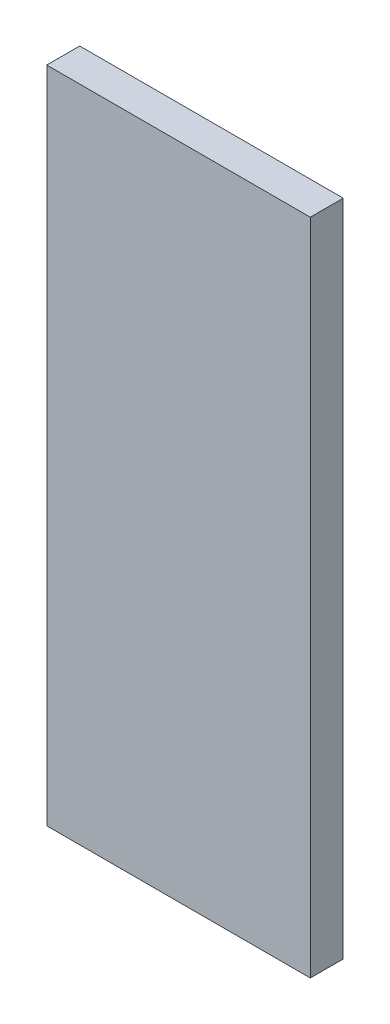
from build123d import *

# Parameters (mm, degrees)
CROQUIS1_W              = 20
CROQUIS1_H              = 50
SALIENTE_EXTRUIR1_DEPTH = 2.5


with BuildPart() as part:
    # Croquis1 → Saliente-Extruir1 (new body)
    with BuildSketch(Plane.XY):
        with Locations((10, 25)):
            Rectangle(CROQUIS1_W, CROQUIS1_H)
    extrude(amount=SALIENTE_EXTRUIR1_DEPTH)


solid = part.part
